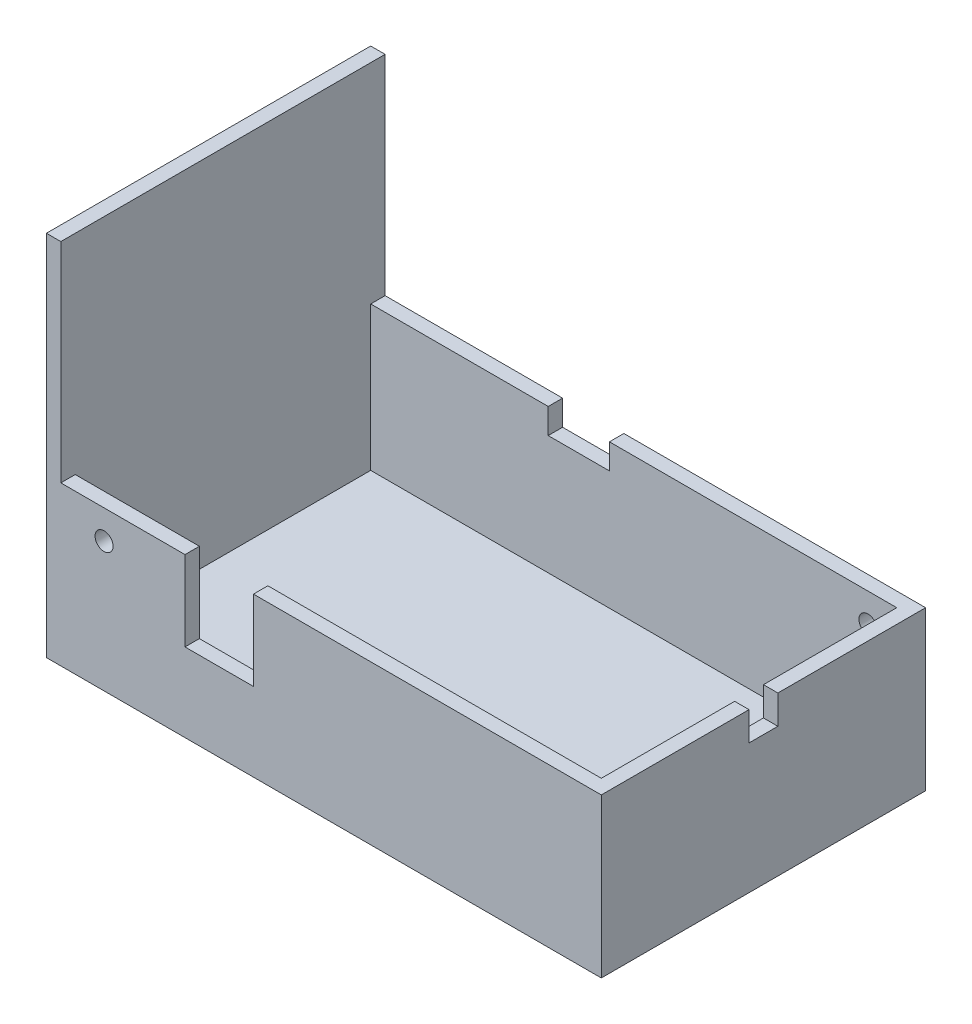
from build123d import *

# Parameters (mm, degrees)
SKETCH1_W           = 77
SKETCH1_H           = 45
BOSS_EXTRUDE1_DEPTH = 2
SKETCH2_W           = 77
SKETCH2_H           = 45
SKETCH2_W_2         = 73
SKETCH2_H_2         = 41
BOSS_EXTRUDE2_DEPTH = 20
SKETCH3_W           = 2
SKETCH3_H           = 45
BOSS_EXTRUDE3_DEPTH = 29
SKETCH4_R           = 1.25
CUT_EXTRUDE1_DEPTH  = 2
SKETCH5_R           = 1.25
CUT_EXTRUDE2_DEPTH  = 2
SKETCH6_W           = 9.5
SKETCH6_H           = 11.1
CUT_EXTRUDE3_DEPTH  = 2
SKETCH7_W           = 8.5
SKETCH7_H           = 3.5
CUT_EXTRUDE4_DEPTH  = 2
SKETCH8_W           = 4
SKETCH8_H           = 4
CUT_EXTRUDE5_DEPTH  = 2


with BuildPart() as part:
    # Sketch1 → Boss-Extrude1 (new body)
    with BuildSketch(Plane(origin=(0, 0, 0), x_dir=(1, 0, 0), z_dir=(0, 1, 0))):
        Rectangle(SKETCH1_W, SKETCH1_H)
    extrude(amount=BOSS_EXTRUDE1_DEPTH)

    # Sketch2 → Boss-Extrude2 (add)
    with BuildSketch(Plane(origin=(0, 2, 0), x_dir=(1, 0, 0), z_dir=(0, 1, 0))):
        Rectangle(SKETCH2_W, SKETCH2_H)
        Rectangle(SKETCH2_W_2, SKETCH2_H_2, mode=Mode.SUBTRACT)
    extrude(amount=BOSS_EXTRUDE2_DEPTH)

    # Sketch3 → Boss-Extrude3 (add)
    with BuildSketch(Plane(origin=(0, 22, 0), x_dir=(1, 0, 0), z_dir=(0, 1, 0))):
        with Locations((-37.5, 0)):
            Rectangle(SKETCH3_W, SKETCH3_H)
    extrude(amount=BOSS_EXTRUDE3_DEPTH)

    # Sketch4 → Cut-Extrude1 (cut)
    with BuildSketch(Plane(origin=(0, 0, -22.5), x_dir=(-1, 0, 0), z_dir=(0, 0, -1))):
        with Locations((-32.5, 18)):
            Circle(SKETCH4_R)
    extrude(amount=-CUT_EXTRUDE1_DEPTH, mode=Mode.SUBTRACT)

    # Sketch5 → Cut-Extrude2 (cut)
    with BuildSketch(Plane.XY.offset(22.5)):
        with Locations((-30.5, 18)):
            Circle(SKETCH5_R)
    extrude(amount=-CUT_EXTRUDE2_DEPTH, mode=Mode.SUBTRACT)

    # Sketch6 → Cut-Extrude3 (cut)
    with BuildSketch(Plane.XY.offset(22.5)):
        with Locations((-14.52, 16.45)):
            Rectangle(SKETCH6_W, SKETCH6_H)
    extrude(amount=-CUT_EXTRUDE3_DEPTH, mode=Mode.SUBTRACT)

    # Sketch7 → Cut-Extrude4 (cut)
    with BuildSketch(Plane(origin=(0, 0, -22.5), x_dir=(-1, 0, 0), z_dir=(0, 0, -1))):
        with Locations((7.62, 20.25)):
            Rectangle(SKETCH7_W, SKETCH7_H)
    extrude(amount=-CUT_EXTRUDE4_DEPTH, mode=Mode.SUBTRACT)

    # Sketch8 → Cut-Extrude5 (cut)
    with BuildSketch(Plane(origin=(38.5, 0, 0), x_dir=(0, 0, -1), z_dir=(1, 0, 0))):
        with Locations((0, 20)):
            Rectangle(SKETCH8_W, SKETCH8_H)
    extrude(amount=-CUT_EXTRUDE5_DEPTH, mode=Mode.SUBTRACT)


solid = part.part
